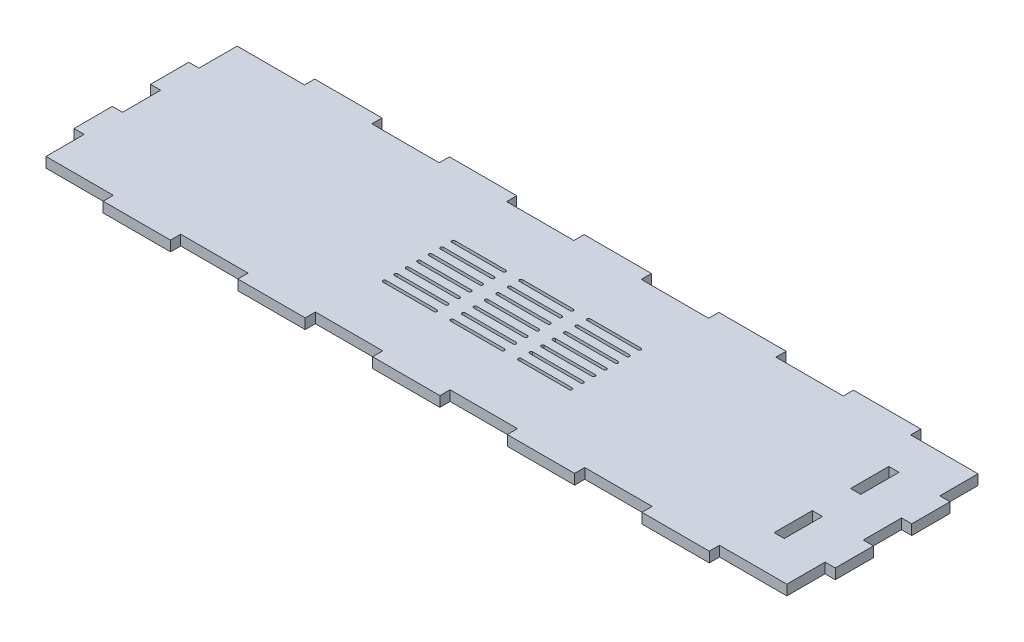
from build123d import *

# Parameters (mm, degrees)
SKETCH1_W           = 436
SKETCH1_H           = 112.5
BOSS_EXTRUDE1_DEPTH = 6
SKETCH2_W           = 22.5
SKETCH2_H           = 6
BOSS_EXTRUDE2_DEPTH = 6
SKETCH3_W           = 39.636363637
SKETCH3_H           = 6
SKETCH3_W_2         = 39.636363636
BOSS_EXTRUDE3_DEPTH = 6
SKETCH4_W           = 6
SKETCH4_H           = 22.5
CUT_EXTRUDE1_DEPTH  = 6
CUT_EXTRUDE2_DEPTH  = 7


with BuildPart() as part:
    # Sketch1 → Boss-Extrude1 (new body)
    with BuildSketch(Plane(origin=(0, 0, 0), x_dir=(1, 0, 0), z_dir=(0, 1, 0))):
        Rectangle(SKETCH1_W, SKETCH1_H)
    extrude(amount=BOSS_EXTRUDE1_DEPTH)

    # Sketch2 → Boss-Extrude2 (add)
    with BuildSketch(Plane.ZY.offset(218)):
        with Locations((-22.5, 3)):
            Rectangle(SKETCH2_W, SKETCH2_H)
        with Locations((22.5, 3)):
            Rectangle(SKETCH2_W, SKETCH2_H)
    boss_extrude2 = extrude(amount=BOSS_EXTRUDE2_DEPTH)

    # Mirror1: Boss-Extrude2 across plane
    add(boss_extrude2.mirror(Plane(origin=(0, 0, 0), x_dir=(0, 0, 1), z_dir=(1, 0, 0))))

    # Sketch3 → Boss-Extrude3 (add)
    with BuildSketch(Plane(origin=(0, 0, -56.25), x_dir=(-1, 0, 0), z_dir=(0, 0, -1))):
        with Locations((158.545454546, 3)):
            Rectangle(SKETCH3_W, SKETCH3_H)
        with Locations((79.272727273, 3)):
            Rectangle(SKETCH3_W_2, SKETCH3_H)
        with Locations((0, 3)):
            Rectangle(SKETCH3_W_2, SKETCH3_H)
        with Locations((-79.272727273, 3)):
            Rectangle(SKETCH3_W_2, SKETCH3_H)
        with Locations((-158.545454546, 3)):
            Rectangle(SKETCH3_W, SKETCH3_H)
    boss_extrude3 = extrude(amount=BOSS_EXTRUDE3_DEPTH)

    # Mirror2: Boss-Extrude3 across Front Plane
    add(boss_extrude3.mirror(Plane.XY))

    # Sketch4 → Cut-Extrude1 (cut)
    with BuildSketch(Plane.XZ):
        with Locations((191, 22.5)):
            Rectangle(SKETCH4_W, SKETCH4_H)
        with Locations((191, -22.5)):
            Rectangle(SKETCH4_W, SKETCH4_H)
    extrude(amount=-CUT_EXTRUDE1_DEPTH, mode=Mode.SUBTRACT)

    # Sketch5 → Cut-Extrude2 (cut, through all)
    with BuildSketch(Plane(origin=(0, 6, 0), x_dir=(1, 0, 0), z_dir=(0, 1, 0))):
        with BuildLine():
            Line((-54.8, 21.15), (-24.8, 21.15))
            ThreePointArc((-24.8, 21.15), (-23.9, 20.25), (-24.8, 19.35))
            Line((-24.8, 19.35), (-54.8, 19.35))
            ThreePointArc((-54.8, 19.35), (-55.7, 20.25), (-54.8, 21.15))
        make_face()
        with BuildLine():
            Line((-15, 21.15), (15, 21.15))
            ThreePointArc((15, 21.15), (15.9, 20.25), (15, 19.35))
            Line((15, 19.35), (-15, 19.35))
            ThreePointArc((-15, 19.35), (-15.9, 20.25), (-15, 21.15))
        make_face()
        with BuildLine():
            Line((54.8, 21.15), (24.8, 21.15))
            ThreePointArc((24.8, 21.15), (23.9, 20.25), (24.8, 19.35))
            Line((24.8, 19.35), (54.8, 19.35))
            ThreePointArc((54.8, 19.35), (55.7, 20.25), (54.8, 21.15))
        make_face()
        with BuildLine():
            Line((-54.8, 14.4), (-24.8, 14.4))
            ThreePointArc((-24.8, 14.4), (-23.9, 13.5), (-24.8, 12.6))
            Line((-24.8, 12.6), (-54.8, 12.6))
            ThreePointArc((-54.8, 12.6), (-55.7, 13.5), (-54.8, 14.4))
        make_face()
        with BuildLine():
            Line((-15, 14.4), (15, 14.4))
            ThreePointArc((15, 14.4), (15.9, 13.5), (15, 12.6))
            Line((15, 12.6), (-15, 12.6))
            ThreePointArc((-15, 12.6), (-15.9, 13.5), (-15, 14.4))
        make_face()
        with BuildLine():
            Line((54.8, 14.4), (24.8, 14.4))
            ThreePointArc((24.8, 14.4), (23.9, 13.5), (24.8, 12.6))
            Line((24.8, 12.6), (54.8, 12.6))
            ThreePointArc((54.8, 12.6), (55.7, 13.5), (54.8, 14.4))
        make_face()
        with BuildLine():
            Line((-54.8, 7.65), (-24.8, 7.65))
            ThreePointArc((-24.8, 7.65), (-23.9, 6.75), (-24.8, 5.85))
            Line((-24.8, 5.85), (-54.8, 5.85))
            ThreePointArc((-54.8, 5.85), (-55.7, 6.75), (-54.8, 7.65))
        make_face()
        with BuildLine():
            Line((-15, 7.65), (15, 7.65))
            ThreePointArc((15, 7.65), (15.9, 6.75), (15, 5.85))
            Line((15, 5.85), (-15, 5.85))
            ThreePointArc((-15, 5.85), (-15.9, 6.75), (-15, 7.65))
        make_face()
        with BuildLine():
            Line((54.8, 7.65), (24.8, 7.65))
            ThreePointArc((24.8, 7.65), (23.9, 6.75), (24.8, 5.85))
            Line((24.8, 5.85), (54.8, 5.85))
            ThreePointArc((54.8, 5.85), (55.7, 6.75), (54.8, 7.65))
        make_face()
        with BuildLine():
            Line((-54.8, 0.9), (-24.8, 0.9))
            ThreePointArc((-24.8, 0.9), (-23.9, 0), (-24.8, -0.9))
            Line((-24.8, -0.9), (-54.8, -0.9))
            ThreePointArc((-54.8, -0.9), (-55.7, 0), (-54.8, 0.9))
        make_face()
        with BuildLine():
            Line((-15, 0.9), (15, 0.9))
            ThreePointArc((15, 0.9), (15.9, 0), (15, -0.9))
            Line((15, -0.9), (-15, -0.9))
            ThreePointArc((-15, -0.9), (-15.9, 0), (-15, 0.9))
        make_face()
        with BuildLine():
            Line((54.8, 0.9), (24.8, 0.9))
            ThreePointArc((24.8, 0.9), (23.9, 0), (24.8, -0.9))
            Line((24.8, -0.9), (54.8, -0.9))
            ThreePointArc((54.8, -0.9), (55.7, 0), (54.8, 0.9))
        make_face()
        with BuildLine():
            Line((-54.8, -5.85), (-24.8, -5.85))
            ThreePointArc((-24.8, -5.85), (-23.9, -6.75), (-24.8, -7.65))
            Line((-24.8, -7.65), (-54.8, -7.65))
            ThreePointArc((-54.8, -7.65), (-55.7, -6.75), (-54.8, -5.85))
        make_face()
        with BuildLine():
            Line((-15, -5.85), (15, -5.85))
            ThreePointArc((15, -5.85), (15.9, -6.75), (15, -7.65))
            Line((15, -7.65), (-15, -7.65))
            ThreePointArc((-15, -7.65), (-15.9, -6.75), (-15, -5.85))
        make_face()
        with BuildLine():
            Line((54.8, -5.85), (24.8, -5.85))
            ThreePointArc((24.8, -5.85), (23.9, -6.75), (24.8, -7.65))
            Line((24.8, -7.65), (54.8, -7.65))
            ThreePointArc((54.8, -7.65), (55.7, -6.75), (54.8, -5.85))
        make_face()
        with BuildLine():
            Line((-54.8, -12.6), (-24.8, -12.6))
            ThreePointArc((-24.8, -12.6), (-23.9, -13.5), (-24.8, -14.4))
            Line((-24.8, -14.4), (-54.8, -14.4))
            ThreePointArc((-54.8, -14.4), (-55.7, -13.5), (-54.8, -12.6))
        make_face()
        with BuildLine():
            Line((-15, -12.6), (15, -12.6))
            ThreePointArc((15, -12.6), (15.9, -13.5), (15, -14.4))
            Line((15, -14.4), (-15, -14.4))
            ThreePointArc((-15, -14.4), (-15.9, -13.5), (-15, -12.6))
        make_face()
        with BuildLine():
            Line((54.8, -12.6), (24.8, -12.6))
            ThreePointArc((24.8, -12.6), (23.9, -13.5), (24.8, -14.4))
            Line((24.8, -14.4), (54.8, -14.4))
            ThreePointArc((54.8, -14.4), (55.7, -13.5), (54.8, -12.6))
        make_face()
        with BuildLine():
            Line((-54.8, -19.35), (-24.8, -19.35))
            ThreePointArc((-24.8, -19.35), (-23.9, -20.25), (-24.8, -21.15))
            Line((-24.8, -21.15), (-54.8, -21.15))
            ThreePointArc((-54.8, -21.15), (-55.7, -20.25), (-54.8, -19.35))
        make_face()
        with BuildLine():
            Line((-15, -19.35), (15, -19.35))
            ThreePointArc((15, -19.35), (15.9, -20.25), (15, -21.15))
            Line((15, -21.15), (-15, -21.15))
            ThreePointArc((-15, -21.15), (-15.9, -20.25), (-15, -19.35))
        make_face()
        with BuildLine():
            Line((54.8, -19.35), (24.8, -19.35))
            ThreePointArc((24.8, -19.35), (23.9, -20.25), (24.8, -21.15))
            Line((24.8, -21.15), (54.8, -21.15))
            ThreePointArc((54.8, -21.15), (55.7, -20.25), (54.8, -19.35))
        make_face()
    extrude(amount=-CUT_EXTRUDE2_DEPTH, mode=Mode.SUBTRACT)


solid = part.part
